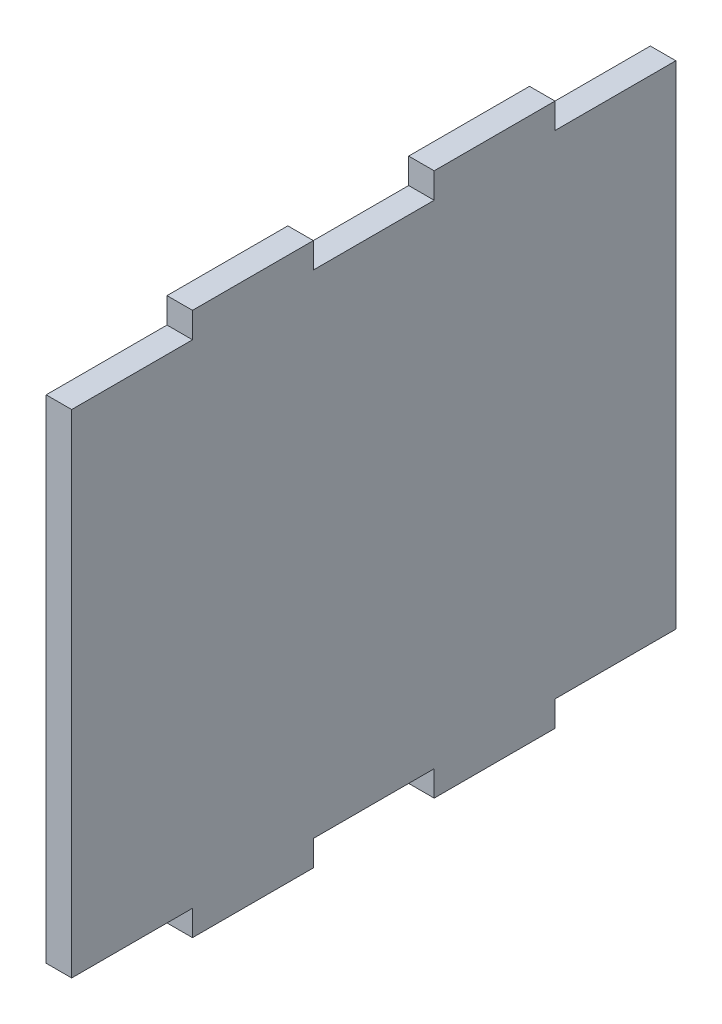
from build123d import *

# Parameters (mm, degrees)
SKETCH1_W           = 135
SKETCH1_H           = 122
BOSS_EXTRUDE1_DEPTH = 5.7
CUT_EXTRUDE1_DEPTH  = 57


with BuildPart() as part:
    # Sketch1 → Boss-Extrude1 (new body)
    with BuildSketch(Plane(origin=(0, 0, 0), x_dir=(0, 0, -1), z_dir=(1, 0, 0))):
        with Locations((67.5, 61)):
            Rectangle(SKETCH1_W, SKETCH1_H)
    extrude(amount=BOSS_EXTRUDE1_DEPTH)

    # Sketch2 → Cut-Extrude1 (cut)
    with BuildSketch(Plane(origin=(0, 0, 0), x_dir=(0, 0, -1), z_dir=(1, 0, 0))):
        Polygon((0, 116), (27, 116), (27, 121.7), (54, 121.7), (54, 116), (81, 116), (81, 121.7), (108, 121.7), (108, 116), (135, 116), (135, 130), (0, 130), align=None)
        Polygon((0, -8), (0, 6), (27, 6), (27, 0.3), (54, 0.3), (54, 6), (81, 6), (81, 0.3), (108, 0.3), (108, 6), (135, 6), (135, -8), align=None)
    extrude(amount=CUT_EXTRUDE1_DEPTH, mode=Mode.SUBTRACT)


solid = part.part
